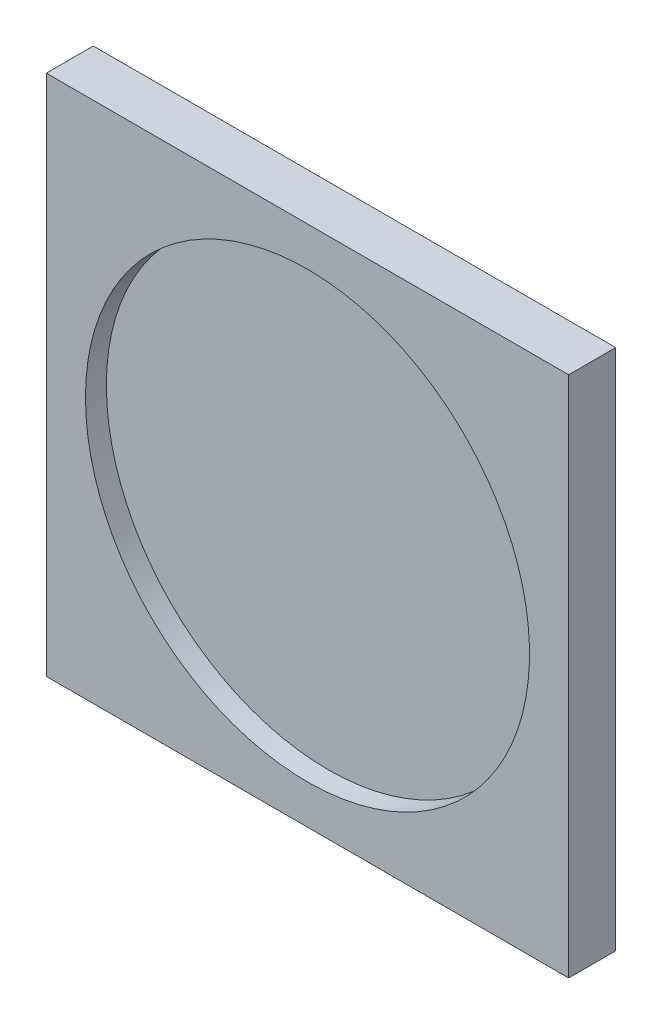
from build123d import *

# Parameters (mm, degrees)
SKETCH4_W               = 100
SKETCH4_H               = 9
BOSS_EXTRUDE3_DEPTH     = 50
SKETCH5_R               = 42.5
CUT_EXTRUDE1_DEPTH      = 1
CUT_EXTRUDE1_DEPTH_BACK = 4


with BuildPart() as part:
    # Sketch4 → Boss-Extrude3 (new body, symmetric)
    with BuildSketch(Plane.YZ):
        with Locations((0, 4.5)):
            Rectangle(SKETCH4_W, SKETCH4_H)
    extrude(amount=BOSS_EXTRUDE3_DEPTH, both=True)

    # Sketch5 → Cut-Extrude1 (cut, two sides)
    with BuildSketch(Plane.XY.offset(9)) as cut_extrude1_sk:
        Circle(SKETCH5_R)
    extrude(amount=CUT_EXTRUDE1_DEPTH, mode=Mode.SUBTRACT)
    extrude(cut_extrude1_sk.sketch, amount=-CUT_EXTRUDE1_DEPTH_BACK, mode=Mode.SUBTRACT)


solid = part.part
